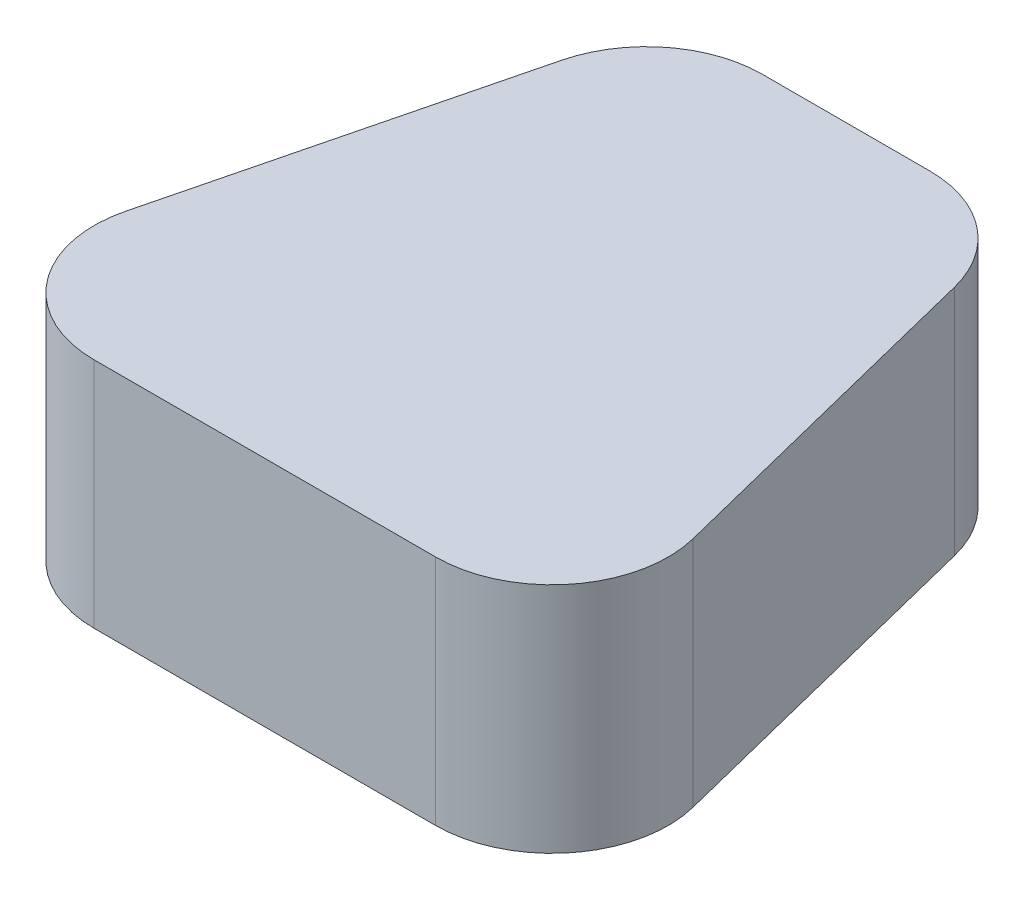
from build123d import *

# Parameters (mm, degrees)
FSHAPE1_DEPTH    = 20
FRSHAPE1_R       = 10
FPIN1ABASE_REACH = 42.935
SPIN1ABASE_R     = 5
FPIN1BBASE_REACH = 42.935
SPIN1BBASE_R     = 5
FPIN2BASE_REACH  = 42.935
SPIN2BASE_R      = 5


with BuildPart() as part:
    # SShape1 → FShape1 (new body)
    with BuildSketch(Plane(origin=(0, 1, 0), x_dir=(1, 0, 0), z_dir=(0, 1, 0))):
        Polygon((-15, 25), (15, 25), (27.5, -25), (-27.5, -25), align=None)
    extrude(amount=FSHAPE1_DEPTH)

    # FRShape1
    frshape1_edges = [part.edges().sort_by_distance(p)[0] for p in [
        (-15, 11, -25),
        (15, 11, -25),
        (27.5, 11, 25),
        (-27.5, 11, 25),
    ]]
    fillet(frshape1_edges, radius=FRSHAPE1_R)

    # SPin1aBase → FPin1aBase (add, up to next)
    with BuildSketch(Plane(origin=(0, 0, 0), x_dir=(1, 0, 0), z_dir=(0, 1, 0)), mode=Mode.PRIVATE) as fpin1abase_sk1:
        with Locations((6.84160069, -3.95)):
            Circle(SPIN1ABASE_R)
    fpin1abase_tool1 = extrude(fpin1abase_sk1.sketch, amount=FPIN1ABASE_REACH, mode=Mode.PRIVATE) - part.part
    add(fpin1abase_tool1.solids().sort_by_distance((6.841601, 0, 3.95))[0])

    # SPin1bBase → FPin1bBase (add, up to next)
    with BuildSketch(Plane(origin=(0, 0, 0), x_dir=(1, 0, 0), z_dir=(0, 1, 0)), mode=Mode.PRIVATE) as fpin1bbase_sk1:
        with Locations((-6.84160069, -3.95)):
            Circle(SPIN1BBASE_R)
    fpin1bbase_tool1 = extrude(fpin1bbase_sk1.sketch, amount=FPIN1BBASE_REACH, mode=Mode.PRIVATE) - part.part
    add(fpin1bbase_tool1.solids().sort_by_distance((-6.841601, 0, 3.95))[0])

    # SPin2Base → FPin2Base (add, up to next)
    with BuildSketch(Plane(origin=(0, 0, 0), x_dir=(1, 0, 0), z_dir=(0, 1, 0)), mode=Mode.PRIVATE) as fpin2base_sk1:
        with Locations((0, 10.3)):
            Circle(SPIN2BASE_R)
    fpin2base_tool1 = extrude(fpin2base_sk1.sketch, amount=FPIN2BASE_REACH, mode=Mode.PRIVATE) - part.part
    add(fpin2base_tool1.solids().sort_by_distance((0, 0, -10.3))[0])


solid = part.part
